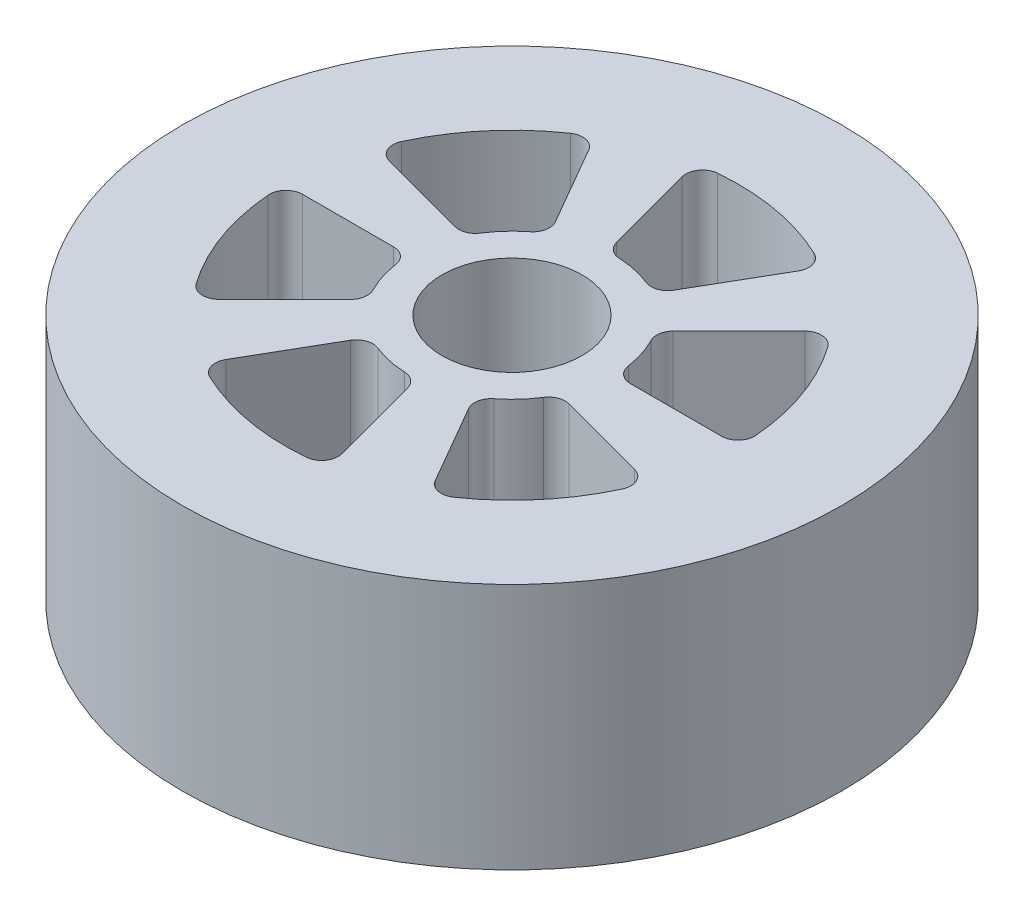
from build123d import *

# Parameters (mm, degrees)
SKETCH1_R           = 101.6
BOSS_EXTRUDE2_DEPTH = 76.2
SKETCH2_R           = 21.59
CUT_EXTRUDE1_DEPTH  = 76.2


with BuildPart() as part:
    # Sketch1 → Boss-Extrude2 (new body)
    with BuildSketch(Plane(origin=(0, 0, 0), x_dir=(1, 0, 0), z_dir=(0, 1, 0))):
        Circle(SKETCH1_R)
        with BuildLine():
            Line((36.477972806, 0), (64.570477, 0))
            ThreePointArc((64.570477, 0), (68.300787401, 1.631640344), (69.634828137, 5.478431373))
            ThreePointArc((69.634828137, 5.478431373), (65.706637707, 23.699372591), (57.099502026, 40.232690295))
            ThreePointArc((57.099502026, 40.232690295), (53.382107886, 42.367992154), (49.354708521, 40.898778904))
            Line((49.354708521, 40.898778904), (29.068878602, 20.612948985))
            ThreePointArc((29.068878602, 20.612948985), (27.639931466, 17.792507776), (28.156018147, 14.673143566))
            ThreePointArc((28.156018147, 14.673143566), (30.242464115, 9.667257328), (31.446528281, 4.379310345))
            ThreePointArc((31.446528281, 4.379310345), (33.142789411, 1.24816601), (36.477972806, 0))
        make_face(mode=Mode.SUBTRACT)
        with BuildLine():
            Line((32.385776769, -14.867912836), (60.096735775, -22.293041923))
            ThreePointArc((60.096735775, -22.293041923), (63.382811455, -25.04626546), (63.392282871, -29.33327415))
            ThreePointArc((63.392282871, -29.33327415), (53.377577571, -45.053931156), (39.56187481, -57.566314469))
            ThreePointArc((39.56187481, -57.566314469), (35.563435689, -58.334396815), (32.2852385, -55.919673416))
            Line((32.2852385, -55.919673416), (18.238986403, -31.590851128))
            ThreePointArc((18.238986403, -31.590851128), (17.652338179, -28.078414577), (19.51585815, -25.043837179))
            ThreePointArc((19.51585815, -25.043837179), (23.493322488, -21.357113533), (26.785324155, -17.047255202))
            ThreePointArc((26.785324155, -17.047255202), (29.228729464, -15.04062892), (32.385776769, -14.867912836))
        make_face(mode=Mode.SUBTRACT)
        with BuildLine():
            Line((3.316898167, -35.480861821), (10.742027254, -63.191820828))
            ThreePointArc((10.742027254, -63.191820828), (10.00070357, -67.414257614), (6.292780846, -69.565964445))
            ThreePointArc((6.292780846, -69.565964445), (-12.329060136, -68.753303747), (-30.072953327, -63.044745841))
            ThreePointArc((-30.072953327, -63.044745841), (-32.737351712, -59.96603716), (-32.2852385, -55.919673416))
            Line((-32.2852385, -55.919673416), (-18.238986403, -31.590851128))
            ThreePointArc((-18.238986403, -31.590851128), (-15.490451232, -29.326580587), (-11.930670131, -29.423147524))
            ThreePointArc((-11.930670131, -29.423147524), (-6.749141627, -31.024370861), (-1.370693992, -31.720398768))
            ThreePointArc((-1.370693992, -31.720398768), (1.588797998, -32.833136696), (3.316898167, -35.480861821))
        make_face(mode=Mode.SUBTRACT)
        with BuildLine():
            Line((-29.068878602, -20.612948985), (-49.354708521, -40.898778904))
            ThreePointArc((-49.354708521, -40.898778904), (-53.382107886, -42.367992154), (-57.099502026, -40.232690295))
            ThreePointArc((-57.099502026, -40.232690295), (-65.706637707, -23.699372591), (-69.634828137, -5.478431373))
            ThreePointArc((-69.634828137, -5.478431373), (-68.300787401, -1.631640344), (-64.570477, 0))
            Line((-64.570477, 0), (-36.477972806, 0))
            ThreePointArc((-36.477972806, 0), (-33.142789411, -1.24816601), (-31.446528281, -4.379310345))
            ThreePointArc((-31.446528281, -4.379310345), (-30.242464115, -9.667257328), (-28.156018147, -14.673143566))
            ThreePointArc((-28.156018147, -14.673143566), (-27.639931466, -17.792507776), (-29.068878602, -20.612948985))
        make_face(mode=Mode.SUBTRACT)
        with BuildLine():
            Line((-32.385776769, 14.867912836), (-60.096735775, 22.293041923))
            ThreePointArc((-60.096735775, 22.293041923), (-63.382811455, 25.04626546), (-63.392282871, 29.33327415))
            ThreePointArc((-63.392282871, 29.33327415), (-53.377577571, 45.053931156), (-39.56187481, 57.566314469))
            ThreePointArc((-39.56187481, 57.566314469), (-35.563435689, 58.334396815), (-32.2852385, 55.919673416))
            Line((-32.2852385, 55.919673416), (-18.238986403, 31.590851128))
            ThreePointArc((-18.238986403, 31.590851128), (-17.652338179, 28.078414577), (-19.51585815, 25.043837179))
            ThreePointArc((-19.51585815, 25.043837179), (-23.493322488, 21.357113533), (-26.785324155, 17.047255202))
            ThreePointArc((-26.785324155, 17.047255202), (-29.228729464, 15.04062892), (-32.385776769, 14.867912836))
        make_face(mode=Mode.SUBTRACT)
        with BuildLine():
            Line((-3.316898167, 35.480861821), (-10.742027254, 63.191820828))
            ThreePointArc((-10.742027254, 63.191820828), (-10.00070357, 67.414257614), (-6.292780846, 69.565964445))
            ThreePointArc((-6.292780846, 69.565964445), (12.329060136, 68.753303747), (30.072953327, 63.044745841))
            ThreePointArc((30.072953327, 63.044745841), (32.737351712, 59.96603716), (32.2852385, 55.919673416))
            Line((32.2852385, 55.919673416), (18.238986403, 31.590851128))
            ThreePointArc((18.238986403, 31.590851128), (15.490451232, 29.326580587), (11.930670131, 29.423147524))
            ThreePointArc((11.930670131, 29.423147524), (6.749141627, 31.024370861), (1.370693992, 31.720398768))
            ThreePointArc((1.370693992, 31.720398768), (-1.588797998, 32.833136696), (-3.316898167, 35.480861821))
        make_face(mode=Mode.SUBTRACT)
    extrude(amount=BOSS_EXTRUDE2_DEPTH)

    # Sketch2 → Cut-Extrude1 (cut)
    with BuildSketch(Plane(origin=(0, 76.2, 0), x_dir=(1, 0, 0), z_dir=(0, 1, 0))):
        Circle(SKETCH2_R)
    extrude(amount=-CUT_EXTRUDE1_DEPTH, mode=Mode.SUBTRACT)


solid = part.part
